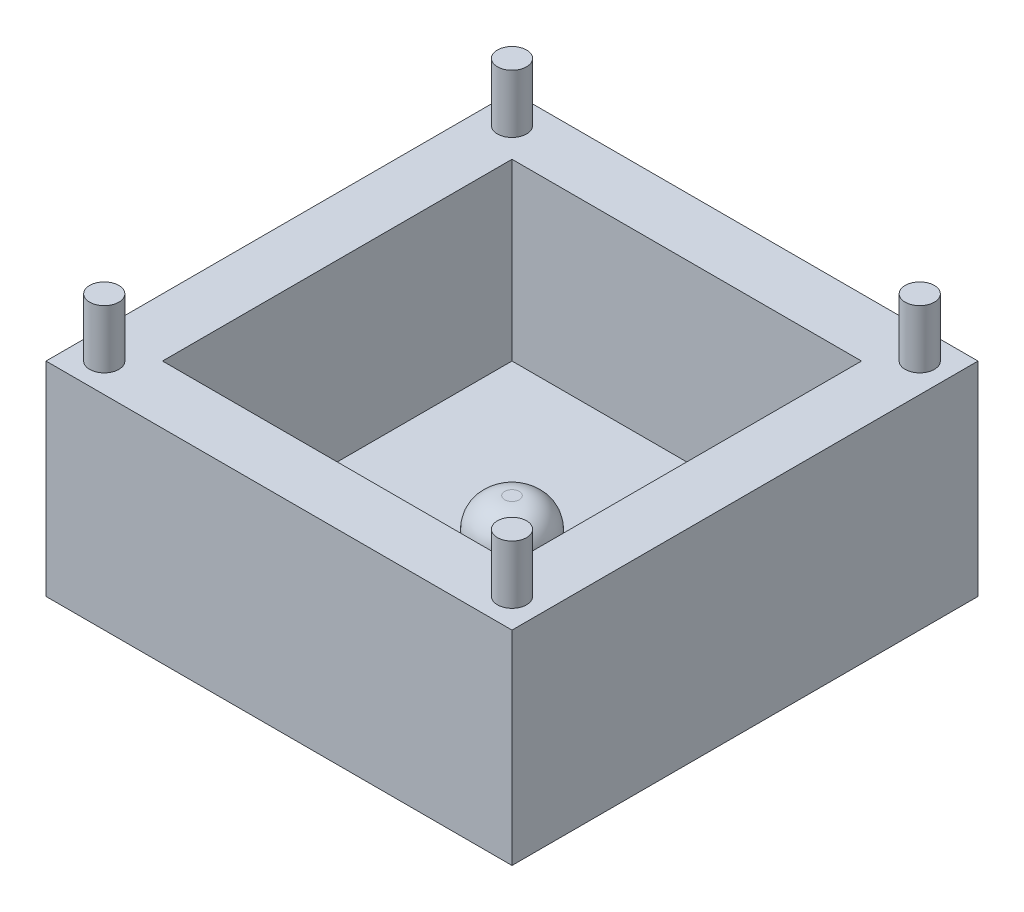
from build123d import *

# Parameters (mm, degrees)
SKETCH1_W           = 16
SKETCH1_H           = 16
BOSS_EXTRUDE1_DEPTH = 7
SKETCH2_W           = 12
SKETCH2_H           = 12
CUT_EXTRUDE1_DEPTH  = 6
SKETCH3_R           = 1.25
BOSS_EXTRUDE2_DEPTH = 2
FILLET1_R           = 1
SKETCH4_R           = 0.5
BOSS_EXTRUDE3_DEPTH = 2


with BuildPart() as part:
    # Sketch1 → Boss-Extrude1 (new body)
    with BuildSketch(Plane(origin=(0, 0, 0), x_dir=(1, 0, 0), z_dir=(0, 1, 0))):
        Rectangle(SKETCH1_W, SKETCH1_H)
    extrude(amount=BOSS_EXTRUDE1_DEPTH)

    # Sketch2 → Cut-Extrude1 (cut)
    with BuildSketch(Plane(origin=(0, 7, 0), x_dir=(1, 0, 0), z_dir=(0, 1, 0))):
        Rectangle(SKETCH2_W, SKETCH2_H)
    extrude(amount=-CUT_EXTRUDE1_DEPTH, mode=Mode.SUBTRACT)

    # Sketch3 → Boss-Extrude2 (add)
    with BuildSketch(Plane(origin=(0, 1, 0), x_dir=(1, 0, 0), z_dir=(0, 1, 0))):
        Circle(SKETCH3_R)
    extrude(amount=BOSS_EXTRUDE2_DEPTH)

    # Fillet1
    fillet1_edges = [part.edges().sort_by_distance(p)[0] for p in [
        (-1.25, 3, 0),
    ]]
    fillet(fillet1_edges, radius=FILLET1_R)

    # Sketch4 → Boss-Extrude3 (add)
    with BuildSketch(Plane(origin=(0, 7, 0), x_dir=(1, 0, 0), z_dir=(0, 1, 0))):
        with Locations((-7, 7)):
            Circle(SKETCH4_R)
        with Locations((7, 7)):
            Circle(SKETCH4_R)
        with Locations((7, -7)):
            Circle(SKETCH4_R)
        with Locations((-7, -7)):
            Circle(SKETCH4_R)
    extrude(amount=BOSS_EXTRUDE3_DEPTH)


solid = part.part
